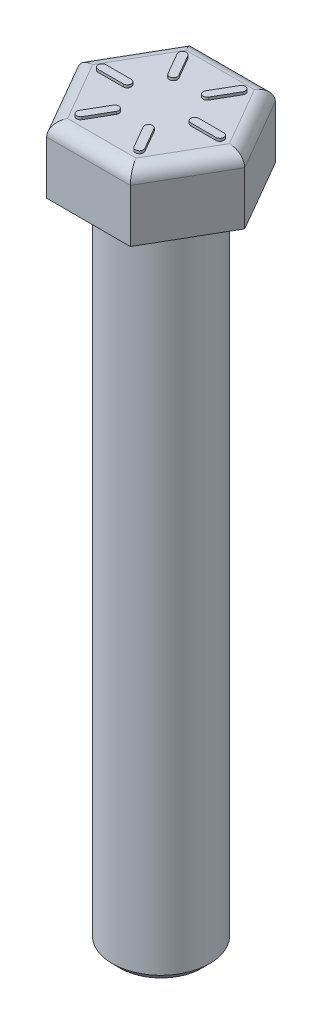
from build123d import *

# Parameters (mm, degrees)
SKETCH1_R           = 4.6609
BOSS_EXTRUDE1_DEPTH = 63.5
BOSS_EXTRUDE2_DEPTH = 6.35
FILLET1_R           = 1.27
CHAMFER1_SIZE       = 0.762
BOSS_EXTRUDE3_DEPTH = 0.254


with BuildPart() as part:
    # Sketch1 → Boss-Extrude1 (new body)
    with BuildSketch(Plane(origin=(0, 0, 0), x_dir=(1, 0, 0), z_dir=(0, 1, 0))):
        Circle(SKETCH1_R)
    extrude(amount=-BOSS_EXTRUDE1_DEPTH)

    # Sketch2 → Boss-Extrude2 (add)
    with BuildSketch(Plane(origin=(0, 0, 0), x_dir=(1, 0, 0), z_dir=(0, 1, 0))):
        Polygon((8.028921518, 0), (4.014460759, 6.95325), (-4.014460759, 6.95325), (-8.028921518, 0), (-4.014460759, -6.95325), (4.014460759, -6.95325), align=None)
    extrude(amount=BOSS_EXTRUDE2_DEPTH)

    # Fillet1
    fillet1_edges = [part.edges().sort_by_distance(p)[0] for p in [
        (6.021691139, 6.35, -3.476625),
        (6.021691139, 6.35, 3.476625),
        (0, 6.35, -6.95325),
        (-6.021691139, 6.35, -3.476625),
        (-6.021691139, 6.35, 3.476625),
        (0, 6.35, 6.95325),
    ]]
    fillet(fillet1_edges, radius=FILLET1_R)

    # Chamfer1
    chamfer1_edges = [part.edges().sort_by_distance(p)[0] for p in [
        (-4.6609, -63.5, 0),
    ]]
    chamfer(chamfer1_edges, length=CHAMFER1_SIZE)

    # Sketch3 → Boss-Extrude3 (add)
    with BuildSketch(Plane(origin=(0, 6.35, 0), x_dir=(1, 0, 0), z_dir=(0, 1, 0))):
        with BuildLine():
            Line((5.6515, -0.381), (3.2385, -0.381))
            ThreePointArc((3.2385, -0.381), (2.8575, 0), (3.2385, 0.381))
            Line((3.2385, 0.381), (5.6515, 0.381))
            ThreePointArc((5.6515, 0.381), (6.0325, 0), (5.6515, -0.381))
        make_face()
        with BuildLine():
            Line((3.155705679, 4.703842569), (1.949205679, 2.61412327))
            ThreePointArc((1.949205679, 2.61412327), (1.42875, 2.474667591), (1.289294321, 2.99512327))
            Line((1.289294321, 2.99512327), (2.495794321, 5.084842569))
            ThreePointArc((2.495794321, 5.084842569), (3.01625, 5.224298248), (3.155705679, 4.703842569))
        make_face()
        with BuildLine():
            Line((-2.495794321, 5.084842569), (-1.289294321, 2.99512327))
            ThreePointArc((-1.289294321, 2.99512327), (-1.42875, 2.474667591), (-1.949205679, 2.61412327))
            Line((-1.949205679, 2.61412327), (-3.155705679, 4.703842569))
            ThreePointArc((-3.155705679, 4.703842569), (-3.01625, 5.224298248), (-2.495794321, 5.084842569))
        make_face()
        with BuildLine():
            Line((-5.6515, 0.381), (-3.2385, 0.381))
            ThreePointArc((-3.2385, 0.381), (-2.8575, 0), (-3.2385, -0.381))
            Line((-3.2385, -0.381), (-5.6515, -0.381))
            ThreePointArc((-5.6515, -0.381), (-6.0325, 0), (-5.6515, 0.381))
        make_face()
        with BuildLine():
            Line((-3.155705679, -4.703842569), (-1.949205679, -2.61412327))
            ThreePointArc((-1.949205679, -2.61412327), (-1.42875, -2.474667591), (-1.289294321, -2.99512327))
            Line((-1.289294321, -2.99512327), (-2.495794321, -5.084842569))
            ThreePointArc((-2.495794321, -5.084842569), (-3.01625, -5.224298248), (-3.155705679, -4.703842569))
        make_face()
        with BuildLine():
            Line((2.495794321, -5.084842569), (1.289294321, -2.99512327))
            ThreePointArc((1.289294321, -2.99512327), (1.42875, -2.474667591), (1.949205679, -2.61412327))
            Line((1.949205679, -2.61412327), (3.155705679, -4.703842569))
            ThreePointArc((3.155705679, -4.703842569), (3.01625, -5.224298248), (2.495794321, -5.084842569))
        make_face()
    extrude(amount=BOSS_EXTRUDE3_DEPTH)


solid = part.part
